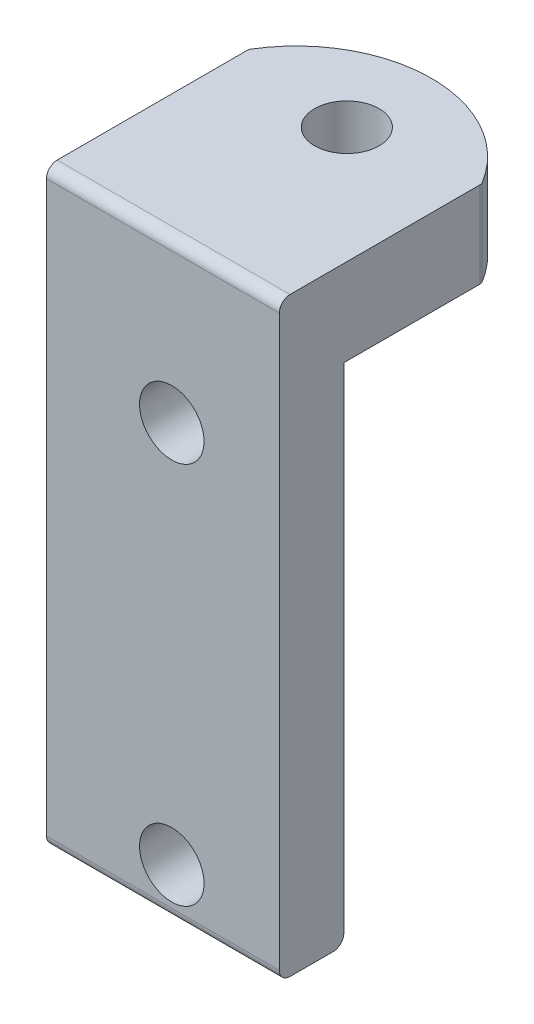
from build123d import *

# Parameters (mm, degrees)
ESBO_O2_R                = 1.5
RESSALTO_EXTRUS_O1_DEPTH = 3
ESBO_O3_R                = 1.5
RESSALTO_EXTRUS_O2_DEPTH = 4
CORTE_EXTRUS_O1_DEPTH    = 800
FILETE3_R                = 0.5
FILETE4_R                = 0.25
FILETE5_R                = 0.25
FILETE6_R                = 0.5


with BuildPart() as part:
    # Esboço2 → Ressalto-extrusão1 (new body)
    with BuildSketch(Plane.XY):
        Polygon((18.673142098, 27.45587681), (18.673142098, 15.094242614), (18.673142098, 10.125059712), (7.844942761, 10.125059712), (7.844942761, 33.593343284), (18.673142098, 33.593343284), align=None)
        with Locations((13.673142098, 30.175059712)):
            Circle(ESBO_O2_R, mode=Mode.SUBTRACT)
        with Locations((13.673142098, 12.375059712)):
            Circle(ESBO_O2_R, mode=Mode.SUBTRACT)
    extrude(amount=RESSALTO_EXTRUS_O1_DEPTH)

    # Esboço3 → Ressalto-extrusão2 (add)
    with BuildSketch(Plane(origin=(0, 33.593343284, 0), x_dir=(1, 0, 0), z_dir=(0, 1, 0))):
        with BuildLine():
            Line((7.844942761, 0), (7.844942761, -3))
            Line((7.844942761, -3), (18.673142098, -3))
            Line((18.673142098, -3), (18.673142098, 0))
            ThreePointArc((18.673142098, 0), (13.25904243, 9.495487225), (7.844942761, 0))
        make_face()
        with Locations((13.25904243, 5.554613856)):
            Circle(ESBO_O3_R, mode=Mode.SUBTRACT)
    extrude(amount=RESSALTO_EXTRUS_O2_DEPTH)

    # Esboço4 → Corte-extrusão1 (cut)
    with BuildSketch(Plane(origin=(0, 0, 0), x_dir=(1, 0, 0), z_dir=(0, 1, 0))):
        with BuildLine():
            Line((7.844942761, 0), (7.844942761, 6.408497108))
            ThreePointArc((7.844942761, 6.408497108), (6.967803758, 3.204248554), (7.844942761, 0))
        make_face()
        with BuildLine():
            Line((18.673142098, 0), (18.673142098, 6.408497108))
            ThreePointArc((18.673142098, 6.408497108), (19.550281101, 3.204248554), (18.673142098, 0))
        make_face()
    extrude(amount=CORTE_EXTRUS_O1_DEPTH, mode=Mode.SUBTRACT)

    # Filete3
    filete3_edges = [part.edges().sort_by_distance(p)[0] for p in [
        (13.25904243, 37.593343284, 3),
    ]]
    fillet(filete3_edges, radius=FILETE3_R)

    # Filete4
    filete4_edges = [part.edges().sort_by_distance(p)[0] for p in [
        (18.673142098, 35.593343284, -6.408497108),
    ]]
    fillet(filete4_edges, radius=FILETE4_R)

    # Filete5
    filete5_edges = [part.edges().sort_by_distance(p)[0] for p in [
        (7.844942761, 35.593343284, -6.408497108),
    ]]
    fillet(filete5_edges, radius=FILETE5_R)

    # Filete6
    filete6_edges = [part.edges().sort_by_distance(p)[0] for p in [
        (13.25904243, 10.125059712, 3),
        (13.25904243, 10.125059712, 0),
    ]]
    fillet(filete6_edges, radius=FILETE6_R)


solid = part.part
